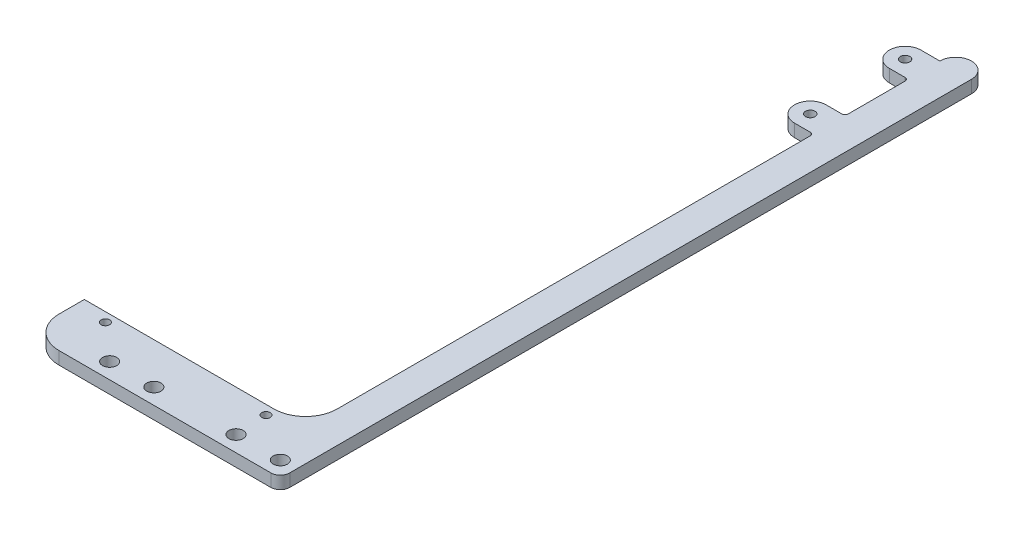
from build123d import *

# Parameters (mm, degrees)
BOSS_EXTRUDE1_DEPTH = 4
SKETCH3_R           = 1.35
SKETCH3_R_2         = 2.25
BOSS_EXTRUDE3_DEPTH = 4
FILLET2_R           = 3
SKETCH6_R           = 1.5
BOSS_EXTRUDE5_DEPTH = 4
FILLET4_R           = 1
FILLET5_R           = 10


with BuildPart() as part:
    # Sketch1 → Boss-Extrude1 (new body)
    with BuildSketch(Plane(origin=(0, 0, 0), x_dir=(1, 0, 0), z_dir=(0, 1, 0))):
        with BuildLine():
            Line((0, 154.95), (0, 0))
            Line((0, 0), (10, 0))
            Line((10, 0), (10, 154.95))
            ThreePointArc((10, 154.95), (5, 159.95), (0, 154.95))
        make_face()
    extrude(amount=BOSS_EXTRUDE1_DEPTH)

    # Sketch3 → Boss-Extrude3 (add)
    with BuildSketch(Plane(origin=(0, 4, 0), x_dir=(1, 0, 0), z_dir=(0, 1, 0))):
        with BuildLine():
            Line((0, 0), (0, -45.7))
            Line((0, -45.7), (-70, -45.7))
            Line((-70, -45.7), (-70, -53.7))
            ThreePointArc((-70, -53.7), (-67.071067812, -60.771067812), (-60, -63.7))
            Line((-60, -63.7), (10, -63.7))
            Line((10, -63.7), (10, 0))
            Line((10, 0), (0, 0))
        make_face()
        with Locations((-60.4, -48.62)):
            Circle(SKETCH3_R, mode=Mode.SUBTRACT)
        with Locations((-49, -58.7)):
            Circle(SKETCH3_R_2, mode=Mode.SUBTRACT)
        with Locations((-35, -58.7)):
            Circle(SKETCH3_R_2, mode=Mode.SUBTRACT)
        with Locations((-9, -58.7)):
            Circle(SKETCH3_R_2, mode=Mode.SUBTRACT)
        with Locations((-9.6, -48.62)):
            Circle(SKETCH3_R, mode=Mode.SUBTRACT)
        with Locations((5, -58.7)):
            Circle(SKETCH3_R_2, mode=Mode.SUBTRACT)
    extrude(amount=-BOSS_EXTRUDE3_DEPTH)

    # Fillet2
    fillet2_edges = [part.edges().sort_by_distance(p)[0] for p in [
        (10, 2, 63.7),
    ]]
    fillet(fillet2_edges, radius=FILLET2_R)

    # Sketch6 → Boss-Extrude5 (add)
    with BuildSketch(Plane(origin=(0, 4, 0), x_dir=(1, 0, 0), z_dir=(0, 1, 0))):
        with BuildLine():
            Line((0, 154.95), (-6, 154.95))
            ThreePointArc((-6, 154.95), (-11, 149.95), (-6, 144.95))
            Line((-6, 144.95), (0, 144.95))
            Line((0, 144.95), (0, 154.95))
        make_face()
        with Locations((-6, 149.95)):
            Circle(SKETCH6_R, mode=Mode.SUBTRACT)
        with BuildLine():
            Line((0, 114.95), (0, 124.95))
            Line((0, 124.95), (-6, 124.95))
            ThreePointArc((-6, 124.95), (-11, 119.95), (-6, 114.95))
            Line((-6, 114.95), (0, 114.95))
        make_face()
        with Locations((-6, 119.95)):
            Circle(SKETCH6_R, mode=Mode.SUBTRACT)
    extrude(amount=-BOSS_EXTRUDE5_DEPTH)

    # Fillet4
    fillet4_edges = [part.edges().sort_by_distance(p)[0] for p in [
        (0, 2, -144.95),
        (0, 2, -124.95),
        (0, 2, -114.95),
    ]]
    fillet(fillet4_edges, radius=FILLET4_R)

    # Fillet5
    fillet5_edges = [part.edges().sort_by_distance(p)[0] for p in [
        (0, 2, 45.7),
    ]]
    fillet(fillet5_edges, radius=FILLET5_R)


solid = part.part
